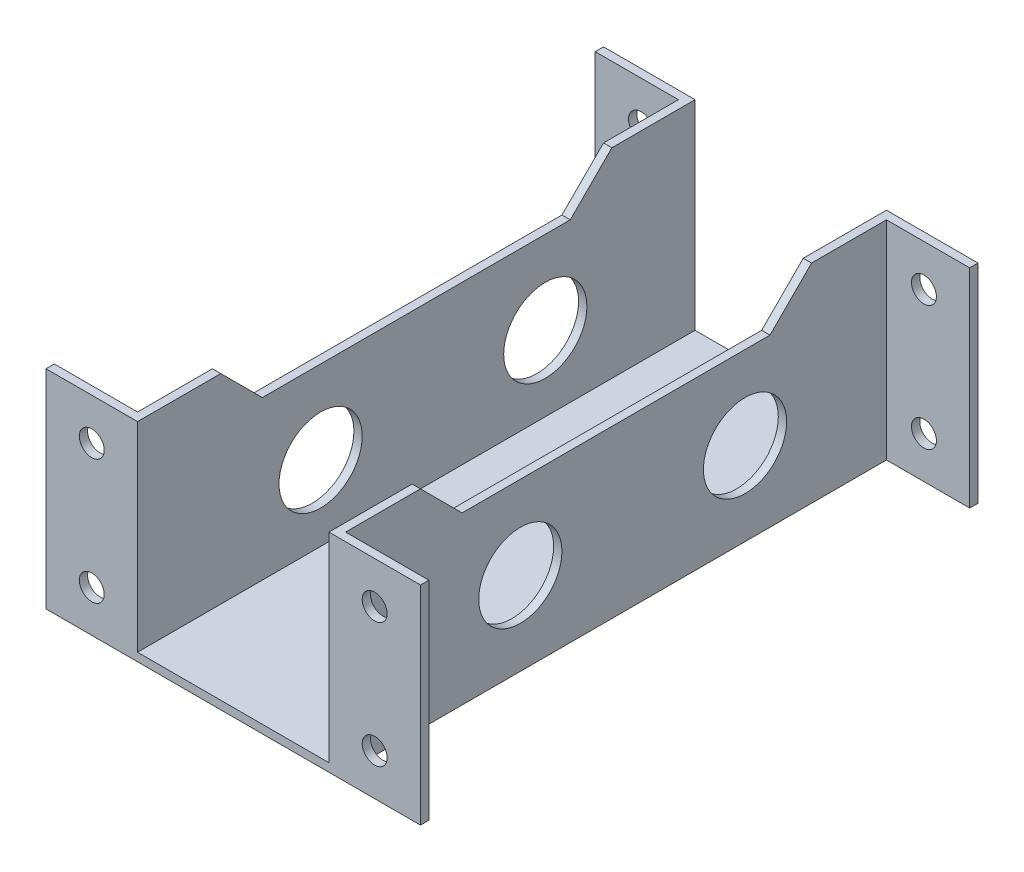
from build123d import *

# Parameters (mm, degrees)
SKETCH1_W               = 25
SKETCH1_H               = 67
BOSS_EXTRUDE1_DEPTH     = 1
SKETCH2_W               = 1
SKETCH2_H               = 67
BOSS_EXTRUDE2_DEPTH     = 24
SKETCH3_W               = 1
SKETCH3_H               = 25
BOSS_EXTRUDE3_DEPTH     = 10
SKETCH4_W               = 1
SKETCH4_H               = 25
BOSS_EXTRUDE4_DEPTH     = 10
SKETCH5_R               = 5
CUT_EXTRUDE1_DEPTH      = 2
SKETCH10_R              = 1.5
CUT_EXTRUDE3_DEPTH      = 68
CUT_EXTRUDE4_DEPTH      = 11
CUT_EXTRUDE4_DEPTH_BACK = 36
SKETCH9_R               = 5
CUT_EXTRUDE2_DEPTH      = 36


with BuildPart() as part:
    # Sketch1 → Boss-Extrude1 (new body)
    with BuildSketch(Plane(origin=(0, 0, 0), x_dir=(1, 0, 0), z_dir=(0, 1, 0))):
        Rectangle(SKETCH1_W, SKETCH1_H)
    extrude(amount=BOSS_EXTRUDE1_DEPTH)

    # Sketch2 → Boss-Extrude2 (add)
    with BuildSketch(Plane(origin=(0, 1, 0), x_dir=(1, 0, 0), z_dir=(0, 1, 0))):
        with Locations((12, 0)):
            Rectangle(SKETCH2_W, SKETCH2_H)
        with Locations((-12, 0)):
            Rectangle(SKETCH2_W, SKETCH2_H)
    extrude(amount=BOSS_EXTRUDE2_DEPTH)

    # Sketch3 → Boss-Extrude3 (add)
    with BuildSketch(Plane(origin=(12.5, 0, 0), x_dir=(0, 0, -1), z_dir=(1, 0, 0))):
        with Locations((-33, 12.5)):
            Rectangle(SKETCH3_W, SKETCH3_H)
        with Locations((33, 12.5)):
            Rectangle(SKETCH3_W, SKETCH3_H)
    extrude(amount=BOSS_EXTRUDE3_DEPTH)

    # Sketch4 → Boss-Extrude4 (add)
    with BuildSketch(Plane.ZY.offset(12.5)):
        with Locations((-33, 12.5)):
            Rectangle(SKETCH4_W, SKETCH4_H)
        with Locations((33, 12.5)):
            Rectangle(SKETCH4_W, SKETCH4_H)
    extrude(amount=BOSS_EXTRUDE4_DEPTH)

    # Sketch5 → Cut-Extrude1 (cut, through all)
    with BuildSketch(Plane(origin=(0, 1, 0), x_dir=(1, 0, 0), z_dir=(0, 1, 0))):
        with Locations((0, -11.5)):
            Circle(SKETCH5_R)
        with Locations((0, 15.5)):
            Circle(SKETCH5_R)
    extrude(amount=-CUT_EXTRUDE1_DEPTH, mode=Mode.SUBTRACT)

    # Sketch10 → Cut-Extrude3 (cut, through all)
    with BuildSketch(Plane.XY.offset(33.5)):
        with Locations((17, 20)):
            Circle(SKETCH10_R)
        with Locations((17, 5)):
            Circle(SKETCH10_R)
        with Locations((-17, 20)):
            Circle(SKETCH10_R)
        with Locations((-17, 5)):
            Circle(SKETCH10_R)
    extrude(amount=-CUT_EXTRUDE3_DEPTH, mode=Mode.SUBTRACT)

    # Sketch11 → Cut-Extrude4 (cut, two sides)
    with BuildSketch(Plane(origin=(12.5, 0, 0), x_dir=(0, 0, -1), z_dir=(1, 0, 0))) as cut_extrude4_sk:
        Polygon((0, 25), (-23.5, 25), (-18.5, 20), (0, 20), align=None)
        Polygon((23.5, 25), (0, 25), (0, 20), (18.5, 20), align=None)
    extrude(amount=CUT_EXTRUDE4_DEPTH, mode=Mode.SUBTRACT)
    extrude(cut_extrude4_sk.sketch, amount=-CUT_EXTRUDE4_DEPTH_BACK, mode=Mode.SUBTRACT)

    # Sketch9 → Cut-Extrude2 (cut, through all)
    with BuildSketch(Plane(origin=(12.5, 0, 0), x_dir=(0, 0, -1), z_dir=(1, 0, 0))):
        with Locations((-11.5, 10)):
            Circle(SKETCH9_R)
        with Locations((15.5, 10)):
            Circle(SKETCH9_R)
    extrude(amount=-CUT_EXTRUDE2_DEPTH, mode=Mode.SUBTRACT)


solid = part.part
